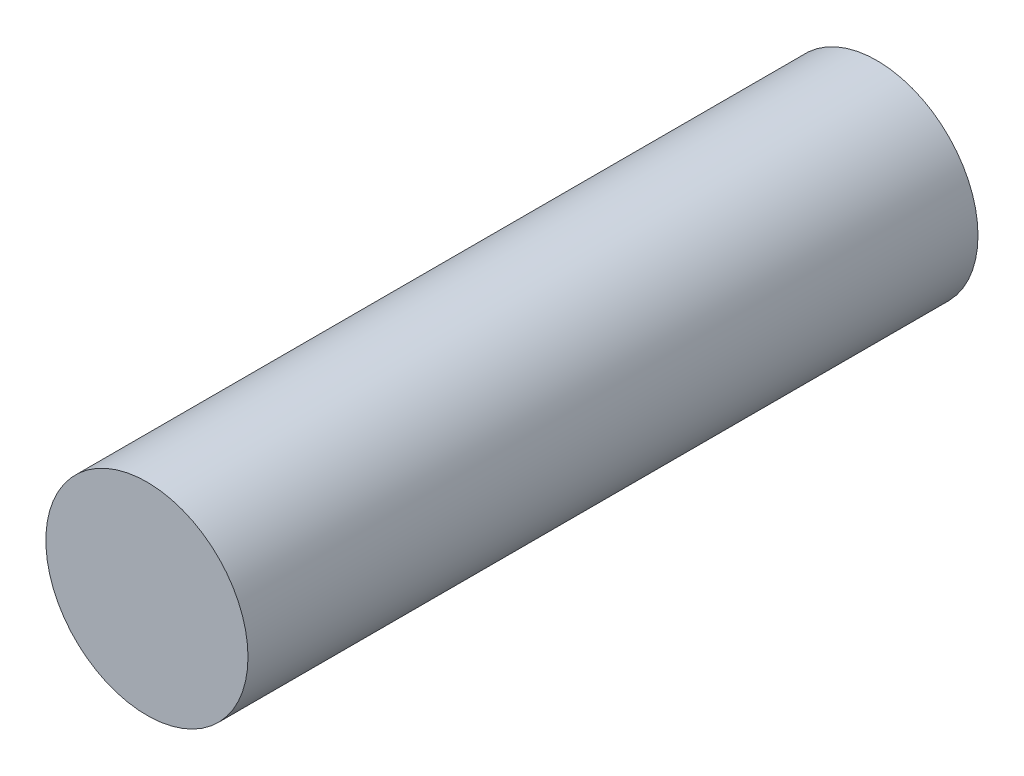
from build123d import *

# Parameters (mm, degrees)
SKETCH_1_R      = 9
EXTRUDE_1_DEPTH = 65


with BuildPart() as part:
    # Эскиз1 → Бобышка-Вытянуть1 (new body)
    with BuildSketch(Plane.XY):
        Circle(SKETCH_1_R)
    extrude(amount=EXTRUDE_1_DEPTH)


solid = part.part
